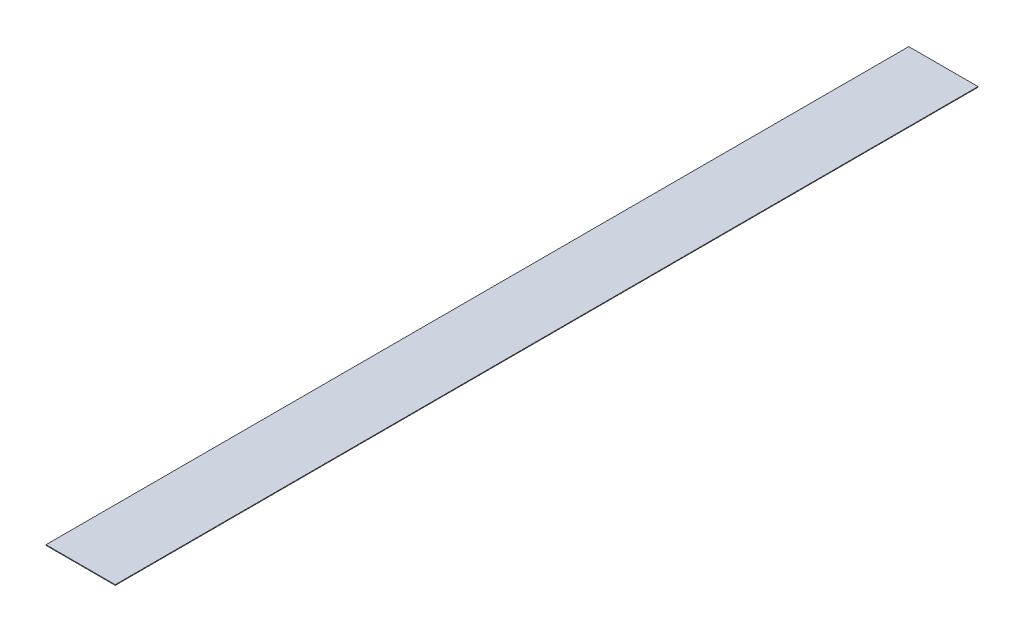
from build123d import *

# Parameters (mm, degrees)
SKETCH1_W      = 24.6054
SKETCH1_H      = 306.5
EXTRUDE1_DEPTH = 0.22


with BuildPart() as part:
    # Sketch1 → Extrude1 (new body)
    with BuildSketch(Plane(origin=(0, 0, 0), x_dir=(1, 0, 0), z_dir=(0, 1, 0))):
        Rectangle(SKETCH1_W, SKETCH1_H)
    extrude(amount=EXTRUDE1_DEPTH)


solid = part.part
